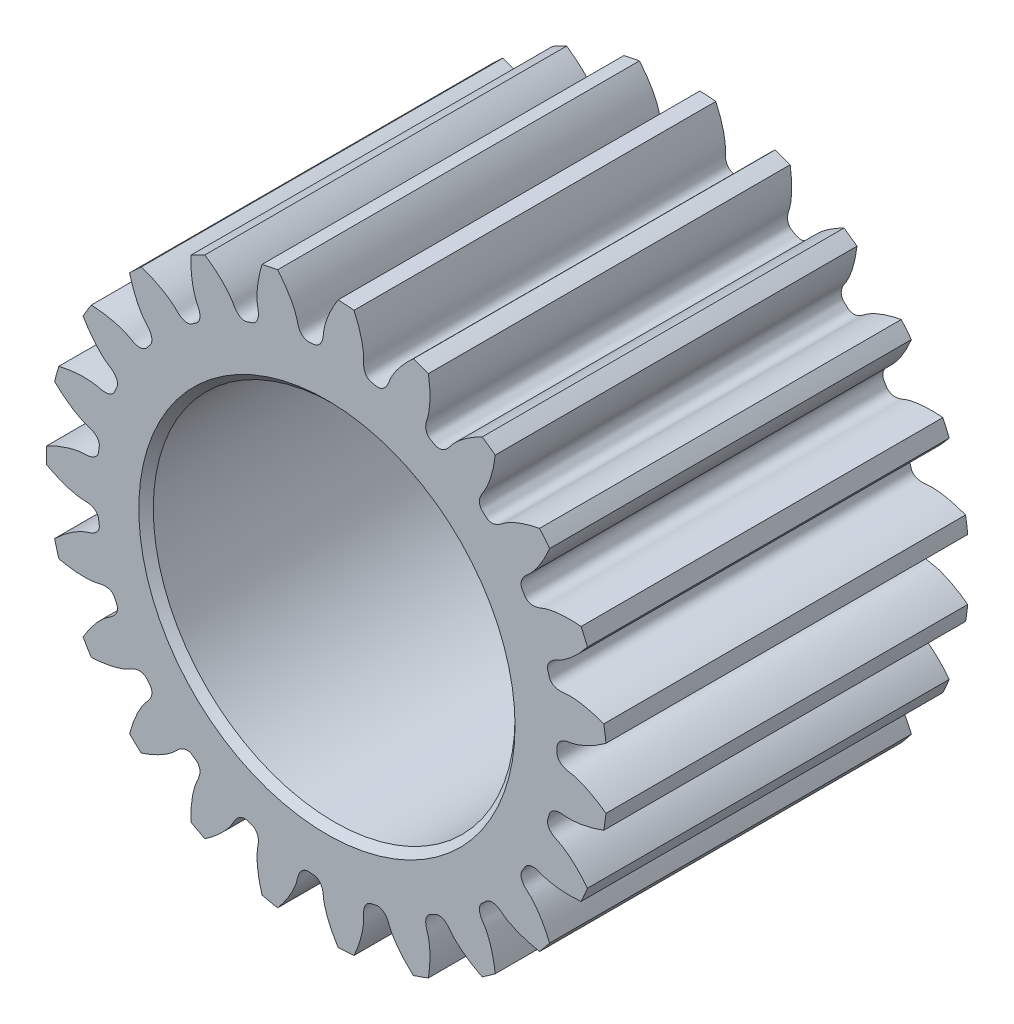
from build123d import *

# Parameters (mm, degrees)
SKETCHREVOLVEPLANET_REVOLVING_FOLLOWER01_W     = 12.7
SKETCHREVOLVEPLANET_REVOLVING_FOLLOWER01_H     = 9.852935244
TOOTHEXTRUDECUTPLANET_REVOLVING_FOLLOWER_DEPTH = 6.35
PATTERNPLANET_REVOLVING_FOLLOWER01_COUNT       = 23


with BuildPart() as part:
    # SketchRevolvePlanet_Revolving_Follower01 → Planet_Revolving_Follower01 (revolve)
    with BuildSketch(Plane(origin=(0, 0, 0), x_dir=(0, 0, -1), z_dir=(1, 0, 0))):
        with Locations((0, 4.926467622)):
            Rectangle(SKETCHREVOLVEPLANET_REVOLVING_FOLLOWER01_W, SKETCHREVOLVEPLANET_REVOLVING_FOLLOWER01_H)
    revolve(axis=Axis((0, 0, 0), (0, 0, -1)))

    # SketchToothPlanet_Revolving_Follower01 → ToothExtrudeCutPlanet_Revolving_Follower (cut, symmetric)
    with BuildSketch(Plane.XY):
        with BuildLine():
            ThreePointArc((9.832023591, 1.09079832), (9.892346985, 0), (9.832023591, -1.09079832))
            add(Edge.make_bspline(
                [(9.832023591, -1.09079832), (9.722132423, -1.0083435), (9.57523223, -0.907106847), (9.389563527, -0.795553246), (9.2891839, -0.73920468), (9.19376669, -0.689283312), (9.103598235, -0.645444349), (9.018948635, -0.607331464), (8.940071474, -0.57457797), (8.867203422, -0.546807292), (8.800563845, -0.523633949), (8.740354626, -0.504663358), (8.686759387, -0.489495339), (8.639944685, -0.4777162), (8.600055356, -0.468925406), (8.543738637, -0.458179359), (8.492838, -0.452145547), (8.446465571, -0.442338288), (8.424993885, -0.43730819), (8.403978154, -0.43179387), (8.383394448, -0.425796742), (8.36322017, -0.419286146), (8.34342945, -0.412230915), (8.323994608, -0.404589141), (8.304886344, -0.396308512), (8.286074775, -0.387323404), (8.26753102, -0.377552358), (8.249229779, -0.366895018), (8.231153322, -0.355228976), (8.21329742, -0.342406813), (8.195679914, -0.328254111), (8.178352548, -0.312569704), (8.161416442, -0.295130209), (8.145040746, -0.275701764), (8.129482195, -0.254062539), (8.115100814, -0.230039038), (8.102361802, -0.203557244), (8.091817972, -0.174700371), (8.084041507, -0.143768284), (8.079887854, -0.113430899), (8.07808617, -0.065335711), (8.080409167, 0), (8.07808617, 0.065335711), (8.079887854, 0.113430899), (8.084041507, 0.143768284), (8.091817972, 0.174700371), (8.102361802, 0.203557244), (8.115100814, 0.230039038), (8.129482195, 0.254062539), (8.145040746, 0.275701764), (8.161416442, 0.295130209), (8.178352548, 0.312569704), (8.195679914, 0.328254111), (8.21329742, 0.342406813), (8.231153322, 0.355228976), (8.249229779, 0.366895018), (8.26753102, 0.377552358), (8.286074775, 0.387323404), (8.304886344, 0.396308512), (8.323994608, 0.404589141), (8.34342945, 0.412230915), (8.36322017, 0.419286146), (8.383394448, 0.425796742), (8.403978154, 0.43179387), (8.424993885, 0.43730819), (8.446465571, 0.442338288), (8.492838, 0.452145547), (8.543738637, 0.458179359), (8.600055356, 0.468925406), (8.639944685, 0.4777162), (8.686759387, 0.489495339), (8.740354626, 0.504663358), (8.800563845, 0.523633949), (8.867203422, 0.546807292), (8.940071474, 0.57457797), (9.018948635, 0.607331464), (9.103598235, 0.645444349), (9.19376669, 0.689283312), (9.2891839, 0.73920468), (9.389563527, 0.795553246), (9.57523223, 0.907106847), (9.722132423, 1.0083435), (9.832023591, 1.09079832)],
                knots=[0, 0, 0, 0, 0.094201438, 0.122209359, 0.148519829, 0.17313285, 0.196048422, 0.217266543, 0.236787215, 0.254610438, 0.27073621, 0.285164533, 0.297895407, 0.308928831, 0.318264805, 0.32590333, 0.348240311, 0.353361839, 0.358400064, 0.363363017, 0.368259858, 0.373101054, 0.377898592, 0.38266622, 0.387419715, 0.392177188, 0.396959392, 0.401790036, 0.406696047, 0.411707719, 0.416858636, 0.422185193, 0.427725485, 0.433517261, 0.439594604, 0.44598316, 0.452694046, 0.459717233, 0.467016123, 0.474525663, 0.480668207, 0.5, 0.519331793, 0.525474337, 0.532983877, 0.540282767, 0.547305954, 0.55401684, 0.560405396, 0.566482739, 0.572274515, 0.577814807, 0.583141364, 0.588292281, 0.593303953, 0.598209964, 0.603040608, 0.607822812, 0.612580285, 0.61733378, 0.622101408, 0.626898946, 0.631740142, 0.636636983, 0.641599936, 0.646638161, 0.651759689, 0.67409667, 0.681735195, 0.691071169, 0.702104593, 0.714835467, 0.72926379, 0.745389562, 0.763212785, 0.782733457, 0.803951578, 0.82686715, 0.851480171, 0.877790641, 0.905798562, 1, 1, 1, 1], degree=3))
        make_face()
    toothextrudecutplanet_revolving_follower = extrude(amount=TOOTHEXTRUDECUTPLANET_REVOLVING_FOLLOWER_DEPTH, both=True, mode=Mode.SUBTRACT)

    # PatternPlanet_Revolving_Follower01: ToothExtrudeCutPlanet_Revolving_Follower ×23 about axis
    patternplanet_revolving_follower01_axis = Axis((0, 0, 55), (0, 0, -1))
    for i in range(1, PATTERNPLANET_REVOLVING_FOLLOWER01_COUNT):
        add(toothextrudecutplanet_revolving_follower.rotate(patternplanet_revolving_follower01_axis, i * 360 / PATTERNPLANET_REVOLVING_FOLLOWER01_COUNT), mode=Mode.SUBTRACT)

    # BoreRevolveSketch → BoreRevolveCut (revolve, cut)
    with BuildSketch(Plane(origin=(0, 0, 0), x_dir=(0, 0, -1), z_dir=(1, 0, 0))):
        Polygon((-6.35, 0), (6.35, 0), (6.35, 6.604), (6.096, 6.35), (-6.096, 6.35), (-6.35, 6.604), align=None)
    revolve(axis=Axis((0, 0, 0), (0, 0, -1)), mode=Mode.SUBTRACT)


solid = part.part
